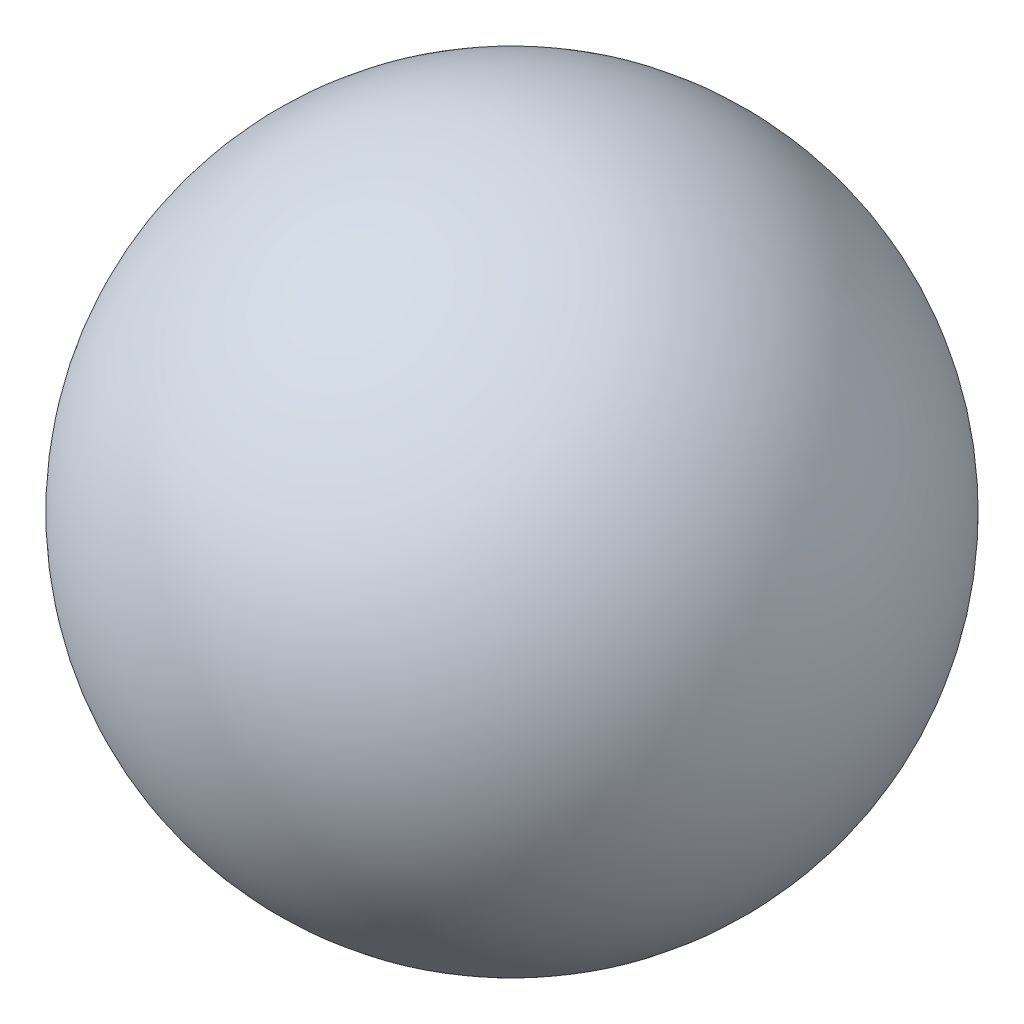
from build123d import *


with BuildPart() as part:
    # Esquisse1 → R_volution1 (revolve)
    with BuildSketch(Plane(origin=(0, 0, 0), x_dir=(-1, 0, 0), z_dir=(0, 0, -1))):
        with BuildLine():
            Line((0, 11), (0, 6))
            ThreePointArc((0, 6), (-2.5, 8.5), (0, 11))
        make_face()
    revolve(axis=Axis((0, 0, 0), (0, 1, 0)))


solid = part.part
